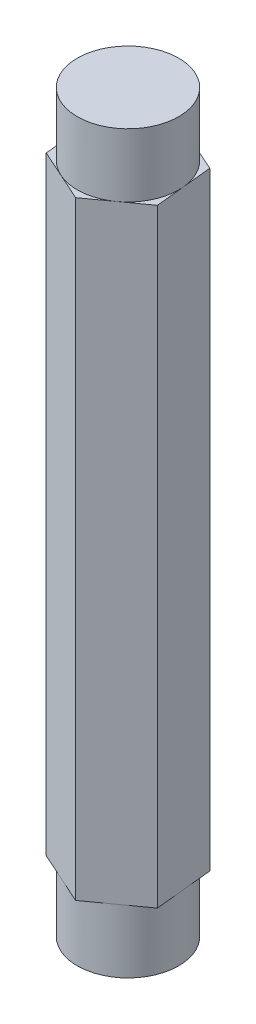
from build123d import *

# Parameters (mm, degrees)
BOSS_EXTRUDE1_DEPTH = 76.2
SKETCH3_R           = 6.35
BOSS_EXTRUDE2_DEPTH = 7.9375
SKETCH4_R           = 6.35
BOSS_EXTRUDE3_DEPTH = 7.9375


with BuildPart() as part:
    # Sketch1 → Boss-Extrude1 (new body)
    with BuildSketch(Plane(origin=(0, 0, 0), x_dir=(1, 0, 0), z_dir=(0, 1, 0))):
        Polygon((5.948792794, 4.286630102), (-0.737934168, 7.295120732), (-6.686726962, 3.008490631), (-5.948792794, -4.286630102), (0.737934168, -7.295120732), (6.686726962, -3.008490631), align=None)
    extrude(amount=BOSS_EXTRUDE1_DEPTH)

    # Sketch3 → Boss-Extrude2 (add)
    with BuildSketch(Plane(origin=(0, 0, 0), x_dir=(-1, 0, 0), z_dir=(0, -1, 0))):
        Circle(SKETCH3_R)
    extrude(amount=BOSS_EXTRUDE2_DEPTH)

    # Sketch4 → Boss-Extrude3 (add)
    with BuildSketch(Plane(origin=(0, 76.2, 0), x_dir=(1, 0, 0), z_dir=(0, 1, 0))):
        Circle(SKETCH4_R)
    extrude(amount=BOSS_EXTRUDE3_DEPTH)


solid = part.part
